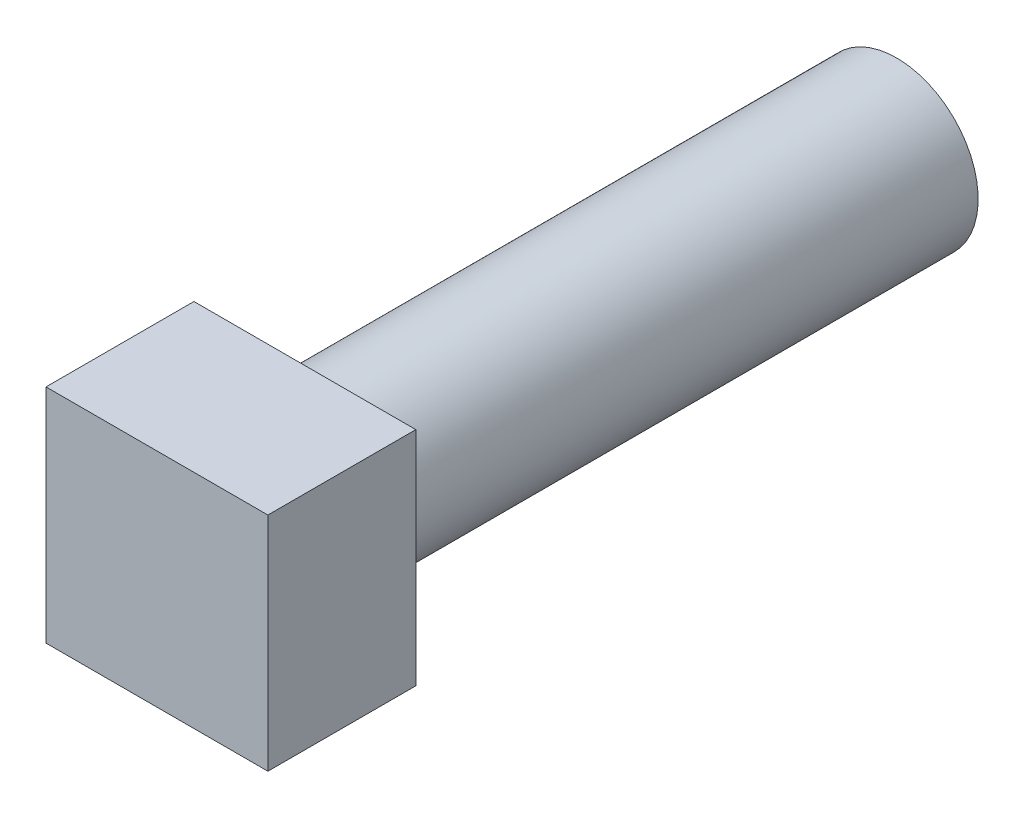
from build123d import *

# Parameters (mm, degrees)
SKETCH1_W           = 9.525
SKETCH1_H           = 9.525
BOSS_EXTRUDE1_DEPTH = 6.35
SKETCH2_R           = 3.5
BOSS_EXTRUDE2_DEPTH = 25.4


with BuildPart() as part:
    # Sketch1 → Boss-Extrude1 (new body)
    with BuildSketch(Plane.XY):
        Rectangle(SKETCH1_W, SKETCH1_H)
    extrude(amount=BOSS_EXTRUDE1_DEPTH)

    # Sketch2 → Boss-Extrude2 (add)
    with BuildSketch(Plane(origin=(0, 0, 0), x_dir=(-1, 0, 0), z_dir=(0, 0, -1))):
        Circle(SKETCH2_R)
    extrude(amount=BOSS_EXTRUDE2_DEPTH)


solid = part.part
